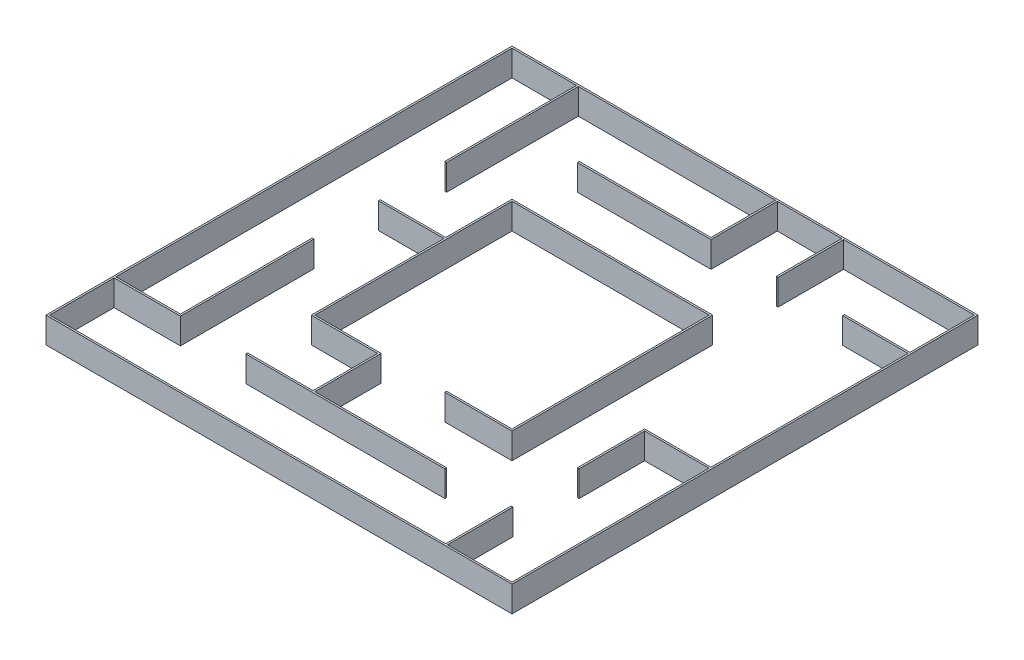
from build123d import *

# Parameters (mm, degrees)
SKETCH1_W           = 2600
SKETCH1_H           = 2600
BOSS_EXTRUDE1_DEPTH = 150
CUT_EXTRUDE1_DEPTH  = 147
BOSS_EXTRUDE2_DEPTH = 147
CUT_EXTRUDE2_REACH  = 1852
SKETCH4_W           = 1100
SKETCH4_H           = 144
SKETCH5_W           = 360
SKETCH5_H           = 360
CUT_EXTRUDE3_DEPTH  = 3
SKETCH6_W           = 360
SKETCH6_H           = 360
CUT_EXTRUDE4_DEPTH  = 3
SKETCH7_W           = 360
SKETCH7_H           = 360
CUT_EXTRUDE5_DEPTH  = 3
CUT_EXTRUDE6_REACH  = 146
SKETCH9_W           = 360
SKETCH9_H           = 360
CUT_EXTRUDE7_REACH  = 146
SKETCH11_W          = 360
SKETCH11_H          = 360
CUT_EXTRUDE8_REACH  = 146
SKETCH13_W          = 360
SKETCH13_H          = 360
CUT_EXTRUDE9_REACH  = 146
SKETCH15_W          = 360
SKETCH15_H          = 360
SKETCH18_W          = 2600
SKETCH18_H          = 2600
CUT_EXTRUDE10_DEPTH = 6


with BuildPart() as part:
    # Sketch1 → Boss-Extrude1 (new body)
    with BuildSketch(Plane(origin=(0, 48.271727257, 0), x_dir=(1, 0, 0), z_dir=(0, 1, 0))):
        with Locations((-22.689229356, -30.131591124)):
            Rectangle(SKETCH1_W, SKETCH1_H)
    extrude(amount=-BOSS_EXTRUDE1_DEPTH)

    # Sketch2 → Cut-Extrude1 (cut)
    with BuildSketch(Plane(origin=(0, 48.271727257, 0), x_dir=(-1, 0, 0), z_dir=(0, 1, 0))):
        Polygon((-902.310770644, -899.868408876), (-907.310770644, -899.868408876), (-907.310770644, -1259.868408876), (-537.310770644, -1259.868408876), (-537.310770644, -894.868408876), (-527.310770644, -894.868408876), (-527.310770644, -1259.868408876), (-167.310770644, -1259.868408876), (-167.310770644, -889.868408876), (577.689229356, -889.868408876), (577.689229356, -899.868408876), (-157.310770644, -899.868408876), (-157.310770644, -1259.868408876), (942.689229356, -1259.868408876), (942.689229356, -524.868408876), (952.689229356, -524.868408876), (952.689229356, -899.868408876), (1312.689229356, -899.868408876), (1312.689229356, 950.131591124), (952.689229356, 950.131591124), (952.689229356, 215.131591124), (942.689229356, 215.131591124), (942.689229356, 960.131591124), (952.689229356, 960.131591124), (952.689229356, 1320.131591124), (-897.310770644, 1320.131591124), (-897.310770644, 955.131591124), (-907.310770644, 955.131591124), (-907.310770644, 960.131591124), (-1267.310770644, 960.131591124), (-1267.310770644, 220.131591124), (-907.310770644, 220.131591124), (-907.310770644, 585.131591124), (-897.310770644, 585.131591124), (-897.310770644, 210.131591124), (-1267.310770644, 210.131591124), (-1267.310770644, -889.868408876), (-902.310770644, -889.868408876), align=None)
    extrude(amount=-CUT_EXTRUDE1_DEPTH, mode=Mode.SUBTRACT)

    # Sketch3 → Boss-Extrude2 (add)
    with BuildSketch(Plane(origin=(0, -98.728272743, 0), x_dir=(-1, 0, 0), z_dir=(0, 1, 0))):
        Polygon((572.689229356, 580.131591124), (202.689229356, 580.131591124), (202.689229356, 950.131591124), (-532.310770644, 950.131591124), (-532.310770644, 960.131591124), (577.689229356, 960.131591124), (577.689229356, 950.131591124), (212.689229356, 950.131591124), (212.689229356, 590.131591124), (582.689229356, 590.131591124), (582.689229356, -149.868408876), (947.689229356, -149.868408876), (947.689229356, -159.868408876), (582.689229356, -159.868408876), (582.689229356, -529.868408876), (-537.310770644, -529.868408876), (-537.310770644, 590.131591124), (-162.310770644, 590.131591124), (-162.310770644, 580.131591124), (-527.310770644, 580.131591124), (-527.310770644, -149.868408876), (572.689229356, -149.868408876), align=None)
    extrude(amount=BOSS_EXTRUDE2_DEPTH)

    # Sketch4 → Cut-Extrude2 (cut, up to next)
    with BuildSketch(Plane(origin=(0, 0, -519.868408876), x_dir=(-1, 0, 0), z_dir=(0, 0, -1)), mode=Mode.PRIVATE) as cut_extrude2_sk1:
        with Locations((22.689229356, -23.728272743)):
            Rectangle(SKETCH4_W, SKETCH4_H)
    cut_extrude2_tool1 = extrude(cut_extrude2_sk1.sketch, amount=-CUT_EXTRUDE2_REACH, mode=Mode.PRIVATE) & part.part
    add(cut_extrude2_tool1.solids().sort_by_distance((-22.689229, -23.728273, -519.868409))[0], mode=Mode.SUBTRACT)

    # Sketch5 → Cut-Extrude3 (cut)
    with BuildSketch(Plane(origin=(0, -95.728272743, 0), x_dir=(-1, 0, 0), z_dir=(0, 1, 0))):
        with Locations((392.689229356, -339.868408876)):
            Rectangle(SKETCH5_W, SKETCH5_H)
    extrude(amount=-CUT_EXTRUDE3_DEPTH, mode=Mode.SUBTRACT)

    # Sketch6 → Cut-Extrude4 (cut)
    with BuildSketch(Plane(origin=(0, -95.728272743, 0), x_dir=(-1, 0, 0), z_dir=(0, 1, 0))):
        with Locations((-347.310770644, -339.868408876)):
            Rectangle(SKETCH6_W, SKETCH6_H)
    extrude(amount=-CUT_EXTRUDE4_DEPTH, mode=Mode.SUBTRACT)

    # Sketch7 → Cut-Extrude5 (cut)
    with BuildSketch(Plane(origin=(0, -95.728272743, 0), x_dir=(-1, 0, 0), z_dir=(0, 1, 0))):
        with Locations((22.689229356, -339.868408876)):
            Rectangle(SKETCH7_W, SKETCH7_H)
    extrude(amount=-CUT_EXTRUDE5_DEPTH, mode=Mode.SUBTRACT)

    # Sketch9 → Cut-Extrude6 (cut, up to next)
    with BuildSketch(Plane.XZ.offset(95.728272743), mode=Mode.PRIVATE) as cut_extrude6_sk1:
        with Locations((1087.310770644, -1079.868408876)):
            Rectangle(SKETCH9_W, SKETCH9_H)
    cut_extrude6_tool1 = extrude(cut_extrude6_sk1.sketch, amount=-CUT_EXTRUDE6_REACH, mode=Mode.PRIVATE) & part.part
    add(cut_extrude6_tool1.solids().sort_by_distance((1087.310771, -95.728273, -1079.868409))[0], mode=Mode.SUBTRACT)

    # Sketch11 → Cut-Extrude7 (cut, up to next)
    with BuildSketch(Plane.XZ.offset(95.728272743), mode=Mode.PRIVATE) as cut_extrude7_sk1:
        with Locations((1087.310770644, 1140.131591124)):
            Rectangle(SKETCH11_W, SKETCH11_H)
    cut_extrude7_tool1 = extrude(cut_extrude7_sk1.sketch, amount=-CUT_EXTRUDE7_REACH, mode=Mode.PRIVATE) & part.part
    add(cut_extrude7_tool1.solids().sort_by_distance((1087.310771, -95.728273, 1140.131591))[0], mode=Mode.SUBTRACT)

    # Sketch13 → Cut-Extrude8 (cut, up to next)
    with BuildSketch(Plane.XZ.offset(95.728272743), mode=Mode.PRIVATE) as cut_extrude8_sk1:
        with Locations((-1132.689229356, 1140.131591124)):
            Rectangle(SKETCH13_W, SKETCH13_H)
    cut_extrude8_tool1 = extrude(cut_extrude8_sk1.sketch, amount=-CUT_EXTRUDE8_REACH, mode=Mode.PRIVATE) & part.part
    add(cut_extrude8_tool1.solids().sort_by_distance((-1132.689229, -95.728273, 1140.131591))[0], mode=Mode.SUBTRACT)

    # Sketch15 → Cut-Extrude9 (cut, up to next)
    with BuildSketch(Plane.XZ.offset(95.728272743), mode=Mode.PRIVATE) as cut_extrude9_sk1:
        with Locations((-1132.689229356, -1079.868408876)):
            Rectangle(SKETCH15_W, SKETCH15_H)
    cut_extrude9_tool1 = extrude(cut_extrude9_sk1.sketch, amount=-CUT_EXTRUDE9_REACH, mode=Mode.PRIVATE) & part.part
    add(cut_extrude9_tool1.solids().sort_by_distance((-1132.689229, -95.728273, -1079.868409))[0], mode=Mode.SUBTRACT)

    # Sketch18 → Cut-Extrude10 (cut)
    with BuildSketch(Plane.XZ.offset(101.728272743)):
        with Locations((-22.689229356, 30.131591124)):
            Rectangle(SKETCH18_W, SKETCH18_H)
    extrude(amount=-CUT_EXTRUDE10_DEPTH, mode=Mode.SUBTRACT)


solid = part.part
